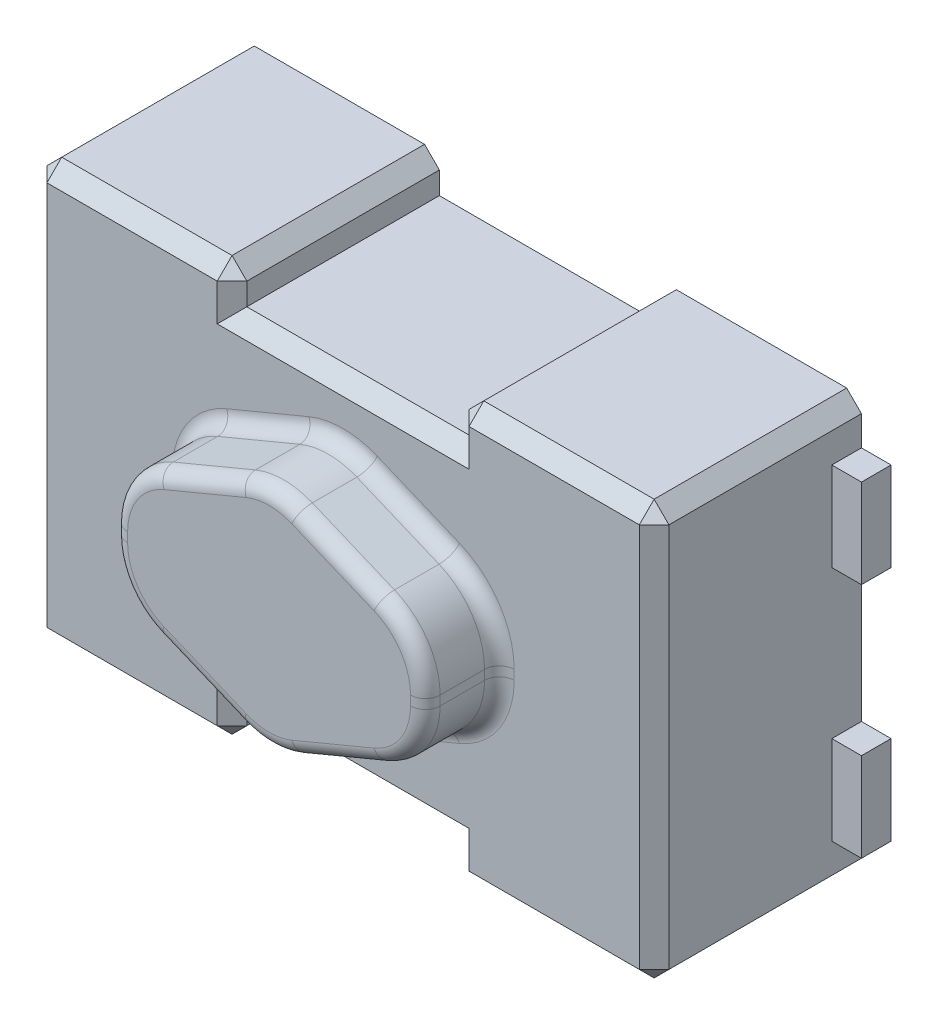
from build123d import *

# Parameters (mm, degrees)
SKETCH1_W           = 4.2
SKETCH1_H           = 2.8
BOSS_EXTRUDE1_DEPTH = 1.4
SKETCH2_W           = 0.2
SKETCH2_H           = 0.6
BOSS_EXTRUDE2_DEPTH = 0.2
SKETCH3_W           = 1.5
SKETCH3_H           = 0.25
CUT_EXTRUDE1_DEPTH  = 2.4
BOSS_EXTRUDE3_DEPTH = 0.5
FILLET1_R           = 0.5
FILLET2_R           = 0.1
CHAMFER1_SIZE       = 0.1


with BuildPart() as part:
    # Sketch1 → Boss-Extrude1 (new body)
    with BuildSketch(Plane.XY):
        with Locations((2.1, 1.4)):
            Rectangle(SKETCH1_W, SKETCH1_H)
    extrude(amount=BOSS_EXTRUDE1_DEPTH)

    # Sketch2 → Boss-Extrude2 (add)
    with BuildSketch(Plane.XY):
        with Locations((4.3, 2.2)):
            Rectangle(SKETCH2_W, SKETCH2_H)
        with Locations((4.3, 0.6)):
            Rectangle(SKETCH2_W, SKETCH2_H)
        with Locations((-0.1, 2.2)):
            Rectangle(SKETCH2_W, SKETCH2_H)
        with Locations((-0.1, 0.6)):
            Rectangle(SKETCH2_W, SKETCH2_H)
    extrude(amount=BOSS_EXTRUDE2_DEPTH)

    # Sketch3 → Cut-Extrude1 (cut, through all)
    with BuildSketch(Plane.XY.offset(1.4)):
        with Locations((2.1, 2.675)):
            Rectangle(SKETCH3_W, SKETCH3_H)
        with Locations((2.1, 0.125)):
            Rectangle(SKETCH3_W, SKETCH3_H)
    extrude(amount=-CUT_EXTRUDE1_DEPTH, mode=Mode.SUBTRACT)

    # Sketch4 → Boss-Extrude3 (add)
    with BuildSketch(Plane.XY.offset(1.4)):
        Polygon((2.1, 2.205), (1.045, 1.765257339), (1.045, 1.034742661), (2.1, 0.595), (3.155, 1.034742661), (3.155, 1.765257339), align=None)
    extrude(amount=BOSS_EXTRUDE3_DEPTH)

    # Fillet1
    fillet1_edges = [part.edges().sort_by_distance(p)[0] for p in [
        (3.155, 1.765257339, 1.65),
        (2.1, 2.205, 1.65),
        (1.045, 1.765257339, 1.65),
        (1.045, 1.034742661, 1.65),
        (2.1, 0.595, 1.65),
        (3.155, 1.034742661, 1.65),
    ]]
    fillet(fillet1_edges, radius=FILLET1_R)

    # Fillet2
    fillet2_edges = [part.edges().sort_by_distance(p)[0] for p in [
        (1.630132921, 2.00915109, 1.4),
        (1.630132921, 2.00915109, 1.9),
        (2.569867079, 2.00915109, 1.4),
        (2.569867079, 2.00915109, 1.9),
        (1.045, 1.4, 1.9),
        (1.630132921, 0.79084891, 1.9),
        (2.569867079, 0.79084891, 1.9),
        (3.155, 1.4, 1.9),
        (2.1, 0.636695714, 1.9),
        (1.12895701, 1.090706199, 1.9),
        (3.07104299, 1.090706199, 1.9),
        (3.07104299, 1.709293801, 1.9),
        (1.12895701, 1.709293801, 1.9),
        (2.1, 2.163304286, 1.9),
        (1.045, 1.4, 1.4),
        (3.155, 1.4, 1.4),
        (2.569867079, 0.79084891, 1.4),
        (1.630132921, 0.79084891, 1.4),
        (2.1, 2.163304286, 1.4),
        (1.12895701, 1.709293801, 1.4),
        (3.07104299, 1.709293801, 1.4),
        (3.07104299, 1.090706199, 1.4),
        (1.12895701, 1.090706199, 1.4),
        (2.1, 0.636695714, 1.4),
    ]]
    fillet(fillet2_edges, radius=FILLET2_R)

    # Chamfer1
    chamfer1_edges = [part.edges().sort_by_distance(p)[0] for p in [
        (4.2, 2.8, 0.7),
        (2.85, 2.8, 0.7),
        (1.35, 2.8, 0.7),
        (0, 2.8, 0.7),
        (0, 0, 0.7),
        (1.35, 0, 0.7),
        (2.85, 0, 0.7),
        (4.2, 0, 0.7),
        (4.2, 1.4, 1.4),
        (3.525, 2.8, 1.4),
        (2.85, 2.675, 1.4),
        (2.1, 2.55, 1.4),
        (1.35, 2.675, 1.4),
        (0.675, 2.8, 1.4),
        (0, 1.4, 1.4),
        (3.525, 0, 1.4),
        (2.85, 0.125, 1.4),
        (2.1, 0.25, 1.4),
        (1.35, 0.125, 1.4),
        (0.675, 0, 1.4),
    ]]
    chamfer(chamfer1_edges, length=CHAMFER1_SIZE)


solid = part.part
